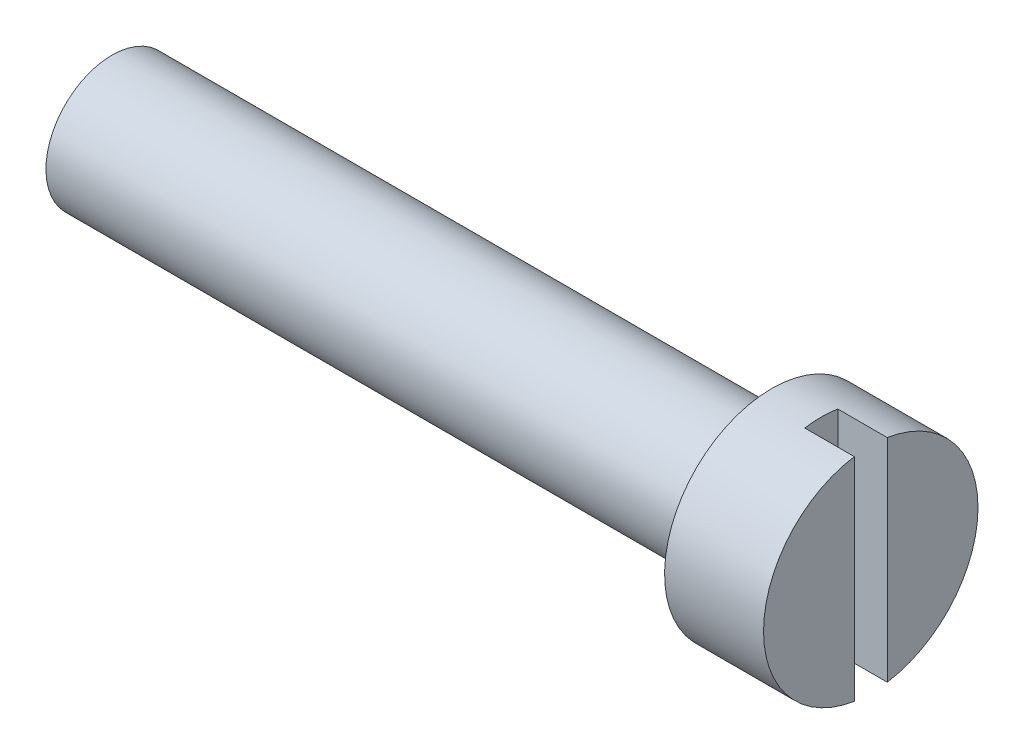
from build123d import *

# Parameters (mm, degrees)
SKETCH2_W          = 1
SKETCH2_H          = 6.5
CUT_EXTRUDE1_DEPTH = 1.5


with BuildPart() as part:
    # Sketch1 → Revolve1 (revolve)
    with BuildSketch(Plane.XY):
        Polygon((0, 0), (-23, 0), (-23, 2), (-3, 2), (-3, 3.25), (0, 3.25), align=None)
    revolve(axis=Axis((0, 0, 0), (-1, 0, 0)))

    # Sketch2 → Cut-Extrude1 (cut)
    with BuildSketch(Plane(origin=(0, 0, 0), x_dir=(0, 0, -1), z_dir=(1, 0, 0))):
        Rectangle(SKETCH2_W, SKETCH2_H)
    extrude(amount=-CUT_EXTRUDE1_DEPTH, mode=Mode.SUBTRACT)


solid = part.part
